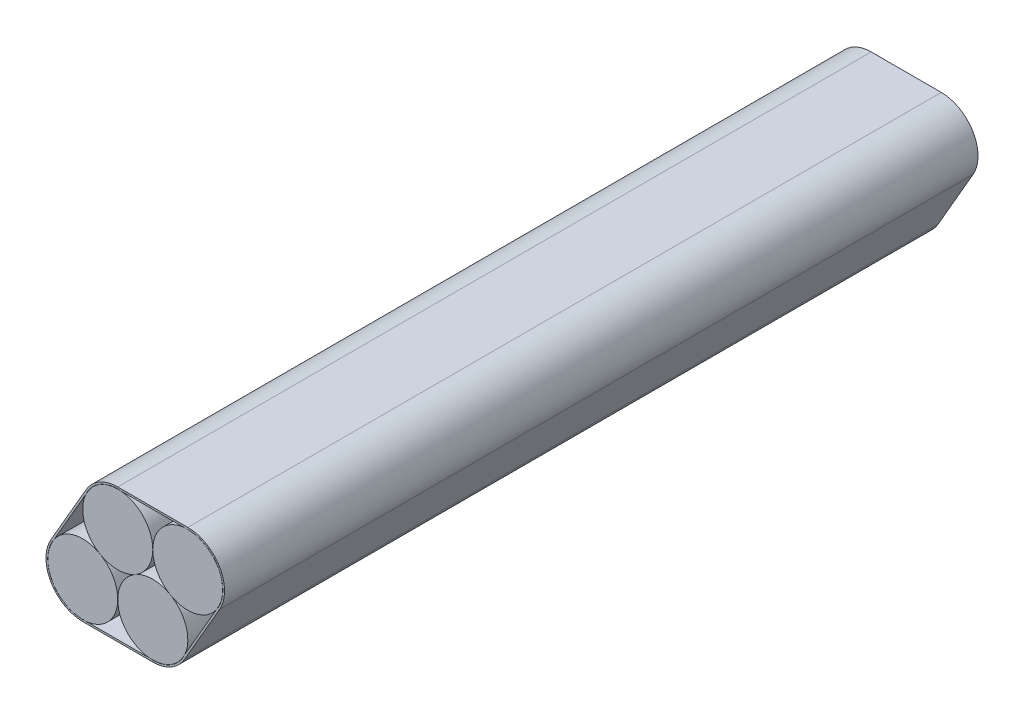
from build123d import *

# Parameters (mm, degrees)
EXTRUDE_1_DEPTH = 200


with BuildPart() as part:
    # Эскиз1 → Бобышка-Вытянуть1 (new body)
    with BuildSketch(Plane.XY):
        with BuildLine():
            Line((27.9, 25.85807251), (9.3, 25.85807251))
            ThreePointArc((9.3, 25.85807251), (4.425, 24.551820197), (0.856252313, 20.98307251))
            Line((0.856252313, 20.98307251), (-8.443747687, 4.875))
            ThreePointArc((-8.443747687, 4.875), (-8.443747687, -4.875), (0, -9.75))
            Line((0, -9.75), (18.6, -9.75))
            ThreePointArc((18.6, -9.75), (23.475, -8.443747687), (27.043747687, -4.875))
            Line((27.043747687, -4.875), (36.343747687, 11.23307251))
            ThreePointArc((36.343747687, 11.23307251), (36.343747687, 20.98307251), (27.9, 25.85807251))
        make_face()
        with BuildLine():
            ThreePointArc((0.807731008, 19.899031145), (4.65, 24.162108766), (10.263068014, 25.35807251))
            Line((10.263068014, 25.35807251), (26.936931986, 25.35807251))
            ThreePointArc((26.936931986, 25.35807251), (35.954036255, 20.75807251), (35.429200978, 10.649031145))
            Line((35.429200978, 10.649031145), (27.092268992, -3.790958634))
            ThreePointArc((27.092268992, -3.790958634), (23.25, -8.054036255), (17.636931986, -9.25))
            Line((17.636931986, -9.25), (0.963068014, -9.25))
            ThreePointArc((0.963068014, -9.25), (-8.054036255, -4.65), (-7.529200978, 5.459041366))
            Line((-7.529200978, 5.459041366), (0.807731008, 19.899031145))
        make_face(mode=Mode.SUBTRACT)
        with BuildLine():
            ThreePointArc((4.650000055, 8.054036223), (-1.938027107, 9.095826017), (-7.529200978, 5.459041366))
            Line((-7.529200978, 5.459041366), (-8.010734985, 4.625))
            ThreePointArc((-8.010734985, 4.625), (-8.010734985, -4.625), (0, -9.25))
            Line((0, -9.25), (0.963068014, -9.25))
            ThreePointArc((0.963068014, -9.25), (6.908202825, -6.22629374), (9.3, 0))
            ThreePointArc((9.3, 0), (8.054036271, 4.649999972), (4.650000055, 8.054036223))
        make_face()
        with BuildLine():
            ThreePointArc((23.250000012, 8.054036248), (18.599999943, 9.3), (13.949999888, 8.054036191))
            ThreePointArc((13.949999888, 8.054036191), (10.545963713, 4.649999944), (9.3, 0))
            ThreePointArc((9.3, 0), (11.691797175, -6.22629374), (17.636931986, -9.25))
            Line((17.636931986, -9.25), (18.6, -9.25))
            ThreePointArc((18.6, -9.25), (23.225, -8.010734985), (26.610734985, -4.625))
            Line((26.610734985, -4.625), (27.092268992, -3.790958634))
            ThreePointArc((27.092268992, -3.790958634), (27.446229965, 2.869532264), (23.250000012, 8.054036248))
        make_face()
        with BuildLine():
            Line((27.9, 25.35807251), (26.936931986, 25.35807251))
            ThreePointArc((26.936931986, 25.35807251), (20.991797175, 22.33436625), (18.6, 16.10807251))
            ThreePointArc((18.6, 16.10807251), (19.845963748, 11.458072504), (23.250000012, 8.054036248))
            ThreePointArc((23.250000012, 8.054036248), (29.838027145, 7.012246501), (35.429200978, 10.649031145))
            Line((35.429200978, 10.649031145), (35.910734985, 11.48307251))
            ThreePointArc((35.910734985, 11.48307251), (35.910734985, 20.73307251), (27.9, 25.35807251))
        make_face()
        with BuildLine():
            Line((10.263068014, 25.35807251), (9.3, 25.35807251))
            ThreePointArc((9.3, 25.35807251), (4.675, 24.118807495), (1.289265015, 20.73307251))
            Line((1.289265015, 20.73307251), (0.807731008, 19.899031145))
            ThreePointArc((0.807731008, 19.899031145), (0.453770047, 13.238540209), (4.650000055, 8.054036223))
            ThreePointArc((4.650000055, 8.054036223), (9.299999967, 6.80807251), (13.949999888, 8.054036191))
            ThreePointArc((13.949999888, 8.054036191), (17.354036223, 11.458072455), (18.6, 16.10807251))
            ThreePointArc((18.6, 16.10807251), (16.208202825, 22.33436625), (10.263068014, 25.35807251))
        make_face()
    extrude(amount=EXTRUDE_1_DEPTH)


solid = part.part
